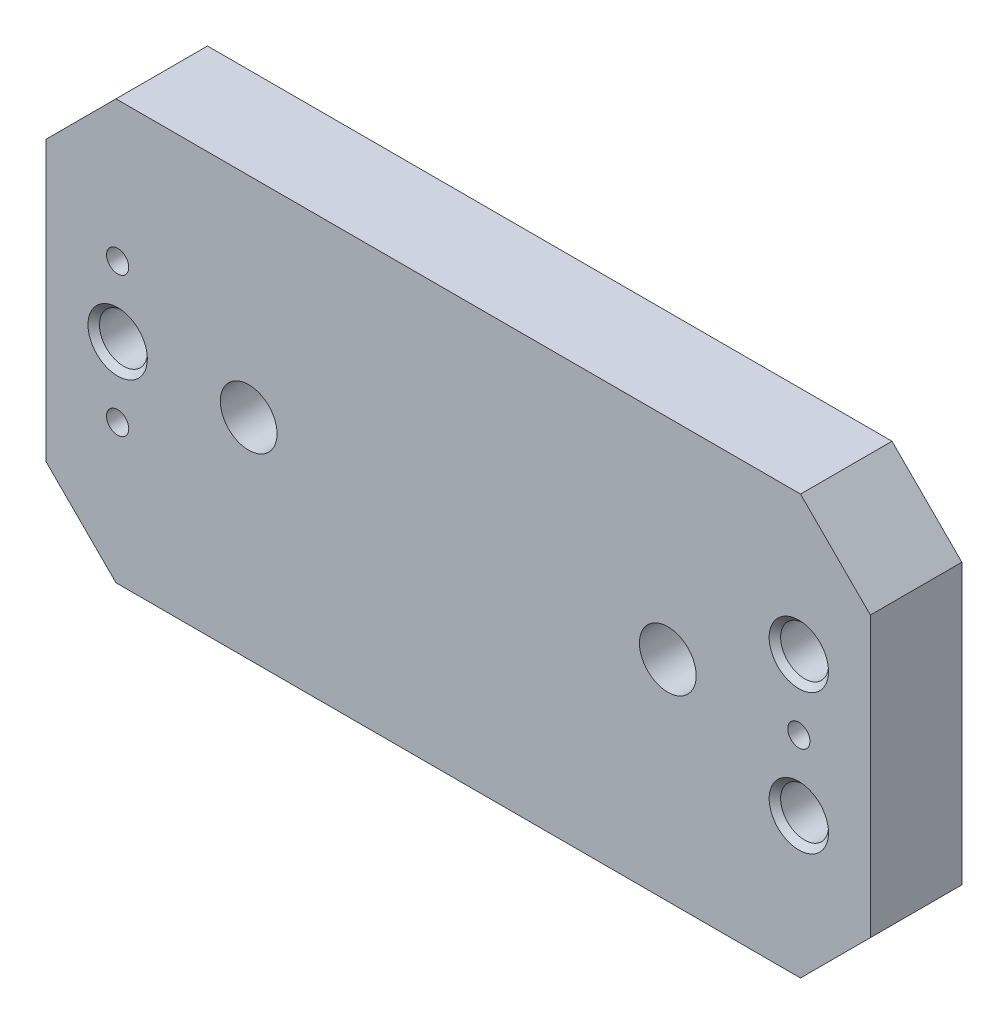
from build123d import *

# Parameters (mm, degrees)
SKETCH1_W                                    = 149.86
SKETCH1_H                                    = 76.2
EXTRUDE1_DEPTH                               = 17.399
SKETCH2_W                                    = 149.86
SKETCH2_H                                    = 76.2
SKETCH2_W_2                                  = 19.05
SKETCH2_H_2                                  = 38.1
CUT_EXTRUDE1_DEPTH                           = 0.762
F_10_32_TAPPED_HOLE1_D                       = 4.0386
CBORE_FOR_10_SOCKET_HEAD_CAP_SCREW1_AT_COUNT = 2
CBORE_FOR_10_SOCKET_HEAD_CAP_SCREW1_AT_PITCH = 25.4
CBORE_FOR_10_SOCKET_HEAD_CAP_SCREW1_2_COUNT  = 2
CBORE_FOR_10_SOCKET_HEAD_CAP_SCREW1_2_PITCH  = 124.499845703
CHAMFER1_SIZE                                = 12.7
SKETCH7_W                                    = 1.5748
SKETCH7_H                                    = 38.1
CUT_EXTRUDE2_DEPTH                           = 0.762
F_13_32_0_40625_DIAMETER_HOLE1_D             = 10.31875


with BuildPart() as part:
    # Sketch1 → Extrude1 (new body)
    with BuildSketch(Plane.XY):
        Rectangle(SKETCH1_W, SKETCH1_H)
    extrude(amount=EXTRUDE1_DEPTH)

    # Sketch2 → Cut-Extrude1 (cut)
    with BuildSketch(Plane(origin=(0, 0, 0), x_dir=(-1, 0, 0), z_dir=(0, 0, -1))):
        Rectangle(SKETCH2_W, SKETCH2_H)
        with Locations((-61.9252, 0)):
            Rectangle(SKETCH2_W_2, SKETCH2_H_2, mode=Mode.SUBTRACT)
        with Locations((61.9252, 0)):
            Rectangle(SKETCH2_W_2, SKETCH2_H_2, mode=Mode.SUBTRACT)
    extrude(amount=-CUT_EXTRUDE1_DEPTH, mode=Mode.SUBTRACT)

    # #10-32 Tapped Hole1 (through all)
    with Locations(Plane.XY.offset(17.399)):
        with Locations((61.9252, 0), (-61.9252, -12.7), (-61.9252, 12.7)):
            Hole(F_10_32_TAPPED_HOLE1_D / 2)

    # Sketch5 → CBORE for #10 Socket Head Cap Screw1 (revolve, cut)
    with BuildSketch(Plane(origin=(61.9252, -12.7, 17.399), x_dir=(0, -1, 0), z_dir=(1, 0, 0))):
        Polygon((0, 0), (0, 17.399), (2.8067, 17.399), (2.8067, 15.0368), (4.3561, 15.0368), (4.3561, 1.0414), (5.3975, 0), align=None)
    cbore_for_10_socket_head_cap_screw1 = revolve(axis=Axis((61.9252, -12.7, 23.749), (0, 0, -1)), mode=Mode.SUBTRACT)

    # CBORE for #10 Socket Head Cap Screw1 at: CBORE for #10 Socket Head Cap Screw1 ×2
    with Locations(*[(0, i * CBORE_FOR_10_SOCKET_HEAD_CAP_SCREW1_AT_PITCH, 0) for i in range(1, CBORE_FOR_10_SOCKET_HEAD_CAP_SCREW1_AT_COUNT)]):
        add(cbore_for_10_socket_head_cap_screw1, mode=Mode.SUBTRACT)

    # CBORE for _10 Socket Head Cap Screw1 2: CBORE for #10 Socket Head Cap Screw1 ×2
    with Locations(*[Vector(-0.994783562, 0.102008159, 0) * (i * CBORE_FOR_10_SOCKET_HEAD_CAP_SCREW1_2_PITCH) for i in range(1, CBORE_FOR_10_SOCKET_HEAD_CAP_SCREW1_2_COUNT)]):
        add(cbore_for_10_socket_head_cap_screw1, mode=Mode.SUBTRACT)

    # Chamfer1
    chamfer1_edges = [part.edges().sort_by_distance(p)[0] for p in [
        (74.93, -38.1, 9.0805),
        (-74.93, -38.1, 9.0805),
        (-74.93, 38.1, 9.0805),
        (74.93, 38.1, 9.0805),
    ]]
    chamfer(chamfer1_edges, length=CHAMFER1_SIZE)

    # Sketch7 → Cut-Extrude2 (cut)
    with BuildSketch(Plane(origin=(0, 0, 0), x_dir=(-1, 0, 0), z_dir=(0, 0, -1))):
        with Locations((61.9252, 0)):
            Rectangle(SKETCH7_W, SKETCH7_H)
        with Locations((-61.9252, 0)):
            Rectangle(SKETCH7_W, SKETCH7_H)
    extrude(amount=-CUT_EXTRUDE2_DEPTH, mode=Mode.SUBTRACT)

    # 13/32 (0.40625) Diameter Hole1 (through all)
    with Locations(Plane.XY.offset(17.399)):
        with Locations((-38.1, 0), (38.1, 0)):
            Hole(F_13_32_0_40625_DIAMETER_HOLE1_D / 2)


solid = part.part
